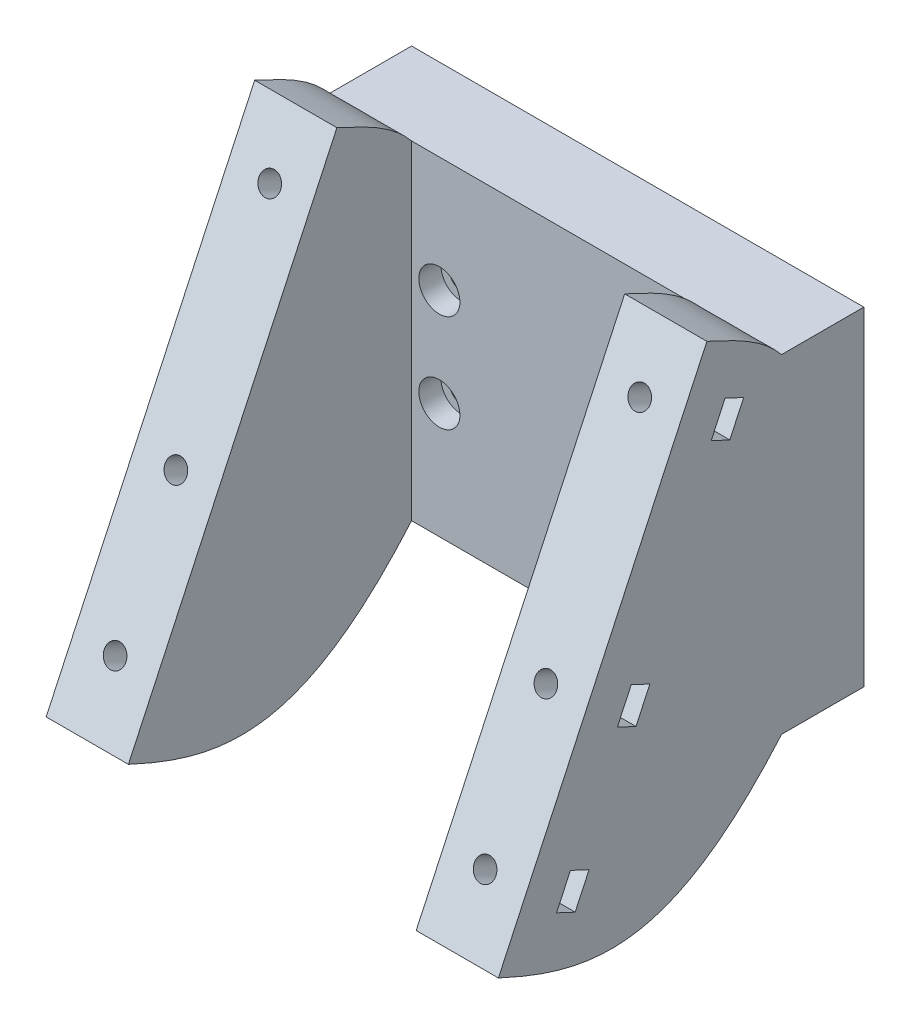
from build123d import *

# Parameters (mm, degrees)
SZKIC1_W                                            = 110
SZKIC1_H                                            = 80
DODANIE_WYCI_GNI_CIE1_DEPTH                         = 20
SZKIC4_W                                            = 20
SZKIC4_H                                            = 140
DODANIE_WYCI_GNI_CIE2_DEPTH                         = 75
WYTNIJ_WYCI_GNI_CIE2_DEPTH                          = 56
WYTNIJ_WYCI_GNI_CIE2_DEPTH_BACK                     = 56
POG_BIENIE_WALCOWE_POD_M5_WKR_T_Z_BEM_W_D           = 5.8
POG_BIENIE_WALCOWE_POD_M5_WKR_T_Z_BEM_W_CBORE_D     = 10
POG_BIENIE_WALCOWE_POD_M5_WKR_T_Z_BEM_W_CBORE_DEPTH = 5.4
WYTNIJ_WYCI_GNI_CIE3_DEPTH                          = 111
SZKIC19_R                                           = 2.65
WYTNIJ_WYCI_GNI_CIE4_DEPTH                          = 20
WYTNIJ_WYCI_GNI_CIE5_DEPTH                          = 5
WYTNIJ_WYCI_GNI_CIE6_DEPTH                          = 10


with BuildPart() as part:
    # Szkic1 → Dodanie-wyciągnięcie1 (new body)
    with BuildSketch(Plane.XY):
        Rectangle(SZKIC1_W, SZKIC1_H)
    extrude(amount=DODANIE_WYCI_GNI_CIE1_DEPTH)

    # Szkic4 → Dodanie-wyciągnięcie2 (add)
    with BuildSketch(Plane.XY.offset(20)):
        with Locations((-45, 0)):
            Rectangle(SZKIC4_W, SZKIC4_H)
        with Locations((45, 0)):
            Rectangle(SZKIC4_W, SZKIC4_H)
    extrude(amount=DODANIE_WYCI_GNI_CIE2_DEPTH)

    # Szkic7 → Wytnij-wyciągnięcie2 (cut, two sides)
    with BuildSketch(Plane(origin=(0, 0, 0), x_dir=(0, 0, -1), z_dir=(1, 0, 0))) as wytnij_wyci_gni_cie2_sk:
        Polygon((-95, -70), (-29.716927858, 70), (-95, 70), align=None)
    extrude(amount=WYTNIJ_WYCI_GNI_CIE2_DEPTH, mode=Mode.SUBTRACT)
    extrude(wytnij_wyci_gni_cie2_sk.sketch, amount=-WYTNIJ_WYCI_GNI_CIE2_DEPTH_BACK, mode=Mode.SUBTRACT)

    # Pogłębienie walcowe pod M5 Wkręt z łbem walcowym z gniazdem sześciokątnym2 (through all)
    with Locations(Plane.XY.offset(20)):
        with Locations((-28.25, 11.906323336), (-28.25, -11.906323336), (28.25, -11.906323336), (28.25, 11.906323336)):
            CounterBoreHole(POG_BIENIE_WALCOWE_POD_M5_WKR_T_Z_BEM_W_D / 2, POG_BIENIE_WALCOWE_POD_M5_WKR_T_Z_BEM_W_CBORE_D / 2, POG_BIENIE_WALCOWE_POD_M5_WKR_T_Z_BEM_W_CBORE_DEPTH)

    # Szkic14 → Wytnij-wyciągnięcie3 (cut, through all)
    with BuildSketch(Plane.ZY.offset(55)):
        with BuildLine():
            add(Edge.make_bspline(
                [(38.169293093, 51.873844259), (31.459464211, 48.744999666), (24.920360639, 45.938457736), (20, 40)],
                knots=[0, 0, 0, 0, 1, 1, 1, 1], degree=3))
            Line((38.169293093, 51.873844259), (29.716927858, 70))
            Line((29.716927858, 70), (20, 70))
            Line((20, 70), (20, 40))
        make_face()
        with BuildLine():
            Line((20, -70), (95, -70))
            Line((95, -70), (88.883484502, -56.883090185))
            add(Edge.make_bspline(
                [(88.883484502, -56.883090185), (65.034975945, -68.003832361), (46.153744311, -70.402204642), (20, -40)],
                knots=[0, 0, 0, 0, 1, 1, 1, 1], degree=3))
            Line((20, -40), (20, -70))
        make_face()
    extrude(amount=-WYTNIJ_WYCI_GNI_CIE3_DEPTH, mode=Mode.SUBTRACT)

    # Szkic19 → Wytnij-wyciągnięcie4 (cut)
    with BuildSketch(Plane(origin=(0, 23.884677387, 51.220855951), x_dir=(1, 0, 0), z_dir=(0, 0.422618262, 0.906307787))):
        with Locations((-45, 15.885667625)):
            Circle(SZKIC19_R)
        with Locations((-45, -73.114332375)):
            Circle(SZKIC19_R)
        with Locations((-45, -38.117371303)):
            Circle(SZKIC19_R)
    wytnij_wyci_gni_cie4 = extrude(amount=-WYTNIJ_WYCI_GNI_CIE4_DEPTH, mode=Mode.SUBTRACT)

    # Szkic20 → Wytnij-wyciągnięcie5 (cut)
    with BuildSketch(Plane(origin=(0, 17.545403461, 37.626239145), x_dir=(1, 0, 0), z_dir=(0, 0.422618262, 0.906307787))):
        Polygon((-42.690598923, 19.885667625), (-47.309401077, 19.885667625), (-49.618802154, 15.885667625), (-47.309401077, 11.885667625), (-42.690598923, 11.885667625), (-40.381197846, 15.885667625), align=None)
        Polygon((-42.690598923, -34.117371303), (-47.309401077, -34.117371303), (-49.618802154, -38.117371303), (-47.309401077, -42.117371303), (-42.690598923, -42.117371303), (-40.381197846, -38.117371303), align=None)
        Polygon((-42.690598923, -69.114332375), (-47.309401077, -69.114332375), (-49.618802154, -73.114332375), (-47.309401077, -77.114332375), (-42.690598923, -77.114332375), (-40.381197846, -73.114332375), align=None)
    wytnij_wyci_gni_cie5 = extrude(amount=WYTNIJ_WYCI_GNI_CIE5_DEPTH, mode=Mode.SUBTRACT)

    # Szkic18 → Wytnij-wyciągnięcie6 (cut)
    with BuildSketch(Plane.ZY.offset(55)):
        Polygon((33.753731795, 37.681030189), (37.134677889, 30.430567893), (32.603138954, 28.317476584), (29.22219286, 35.56793888), align=None)
        Polygon((52.044863301, -13.375435824), (55.425809395, -20.625898121), (59.95734833, -18.512806812), (56.576402236, -11.262344516), align=None)
        Polygon((66.835218155, -45.093454166), (70.216164249, -52.343916462), (74.747703184, -50.230825153), (71.36675709, -42.980362857), align=None)
    wytnij_wyci_gni_cie6 = extrude(amount=-WYTNIJ_WYCI_GNI_CIE6_DEPTH, mode=Mode.SUBTRACT)

    # Lustro2: Wytnij-wyciągnięcie4, Wytnij-wyciągnięcie5, Wytnij-wyciągnięcie6 across plane
    add(wytnij_wyci_gni_cie4.mirror(Plane(origin=(0, 0, 0), x_dir=(0, 0, 1), z_dir=(1, 0, 0))), mode=Mode.SUBTRACT)
    add(wytnij_wyci_gni_cie5.mirror(Plane(origin=(0, 0, 0), x_dir=(0, 0, 1), z_dir=(1, 0, 0))), mode=Mode.SUBTRACT)
    add(wytnij_wyci_gni_cie6.mirror(Plane(origin=(0, 0, 0), x_dir=(0, 0, 1), z_dir=(1, 0, 0))), mode=Mode.SUBTRACT)


solid = part.part
